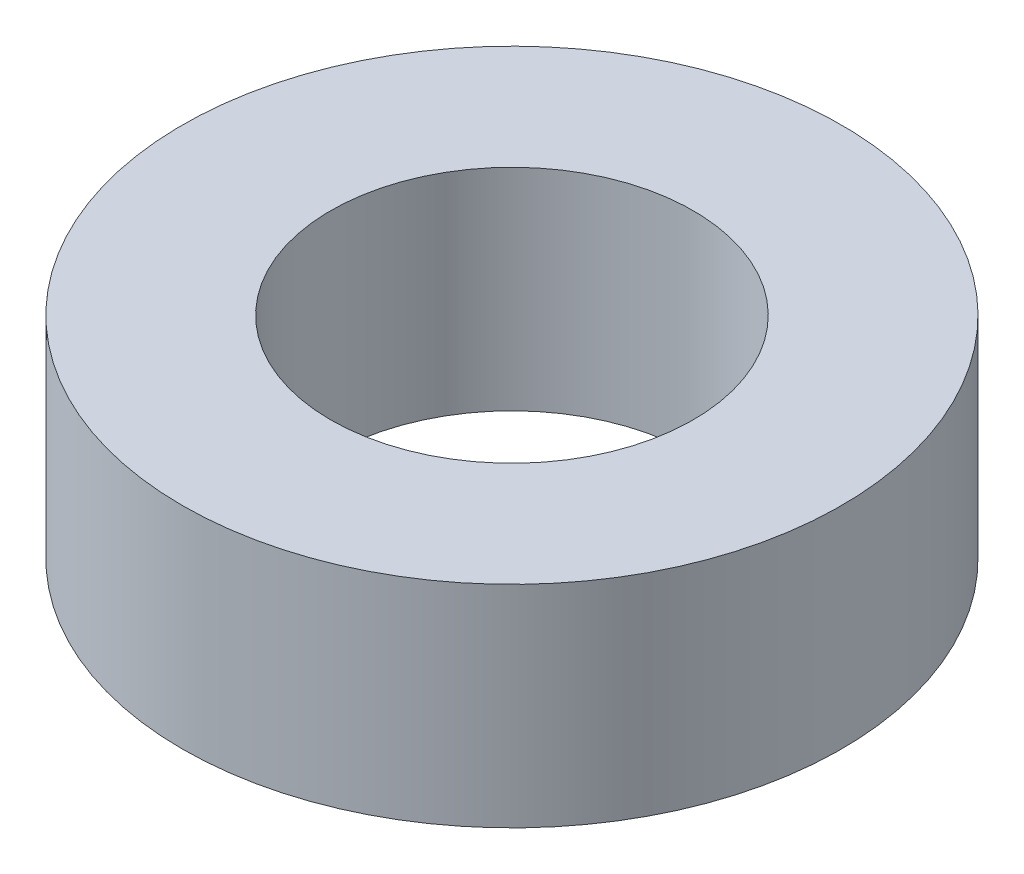
from build123d import *

# Parameters (mm, degrees)
SKETCH1_R           = 5
SKETCH1_R_2         = 2.75
BOSS_EXTRUDE1_DEPTH = 1.6


with BuildPart() as part:
    # Sketch1 → Boss-Extrude1 (new body, symmetric)
    with BuildSketch(Plane(origin=(0, 0, 0), x_dir=(1, 0, 0), z_dir=(0, 1, 0))):
        Circle(SKETCH1_R)
        Circle(SKETCH1_R_2, mode=Mode.SUBTRACT)
    extrude(amount=BOSS_EXTRUDE1_DEPTH, both=True)


solid = part.part
